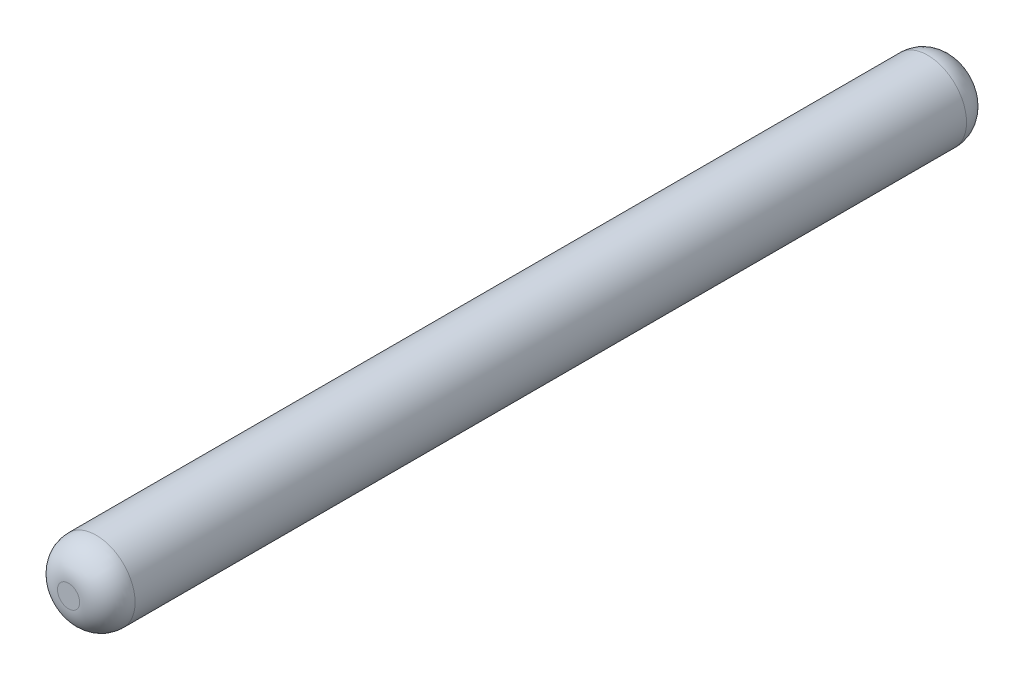
from build123d import *

# Parameters (mm, degrees)
SKIZZE1_R                       = 0.525
AUFSATZ_LINEAR_AUSTRAGEN1_DEPTH = 12
FILLET2_R                       = 0.375


with BuildPart() as part:
    # Skizze1 → Aufsatz-Linear austragen1 (new body)
    with BuildSketch(Plane.XY):
        Circle(SKIZZE1_R)
    extrude(amount=AUFSATZ_LINEAR_AUSTRAGEN1_DEPTH)

    # Fillet2
    fillet2_edges = [part.edges().sort_by_distance(p)[0] for p in [
        (-0.525, 0, 0),
        (-0.525, 0, 12),
    ]]
    fillet(fillet2_edges, radius=FILLET2_R)


solid = part.part
